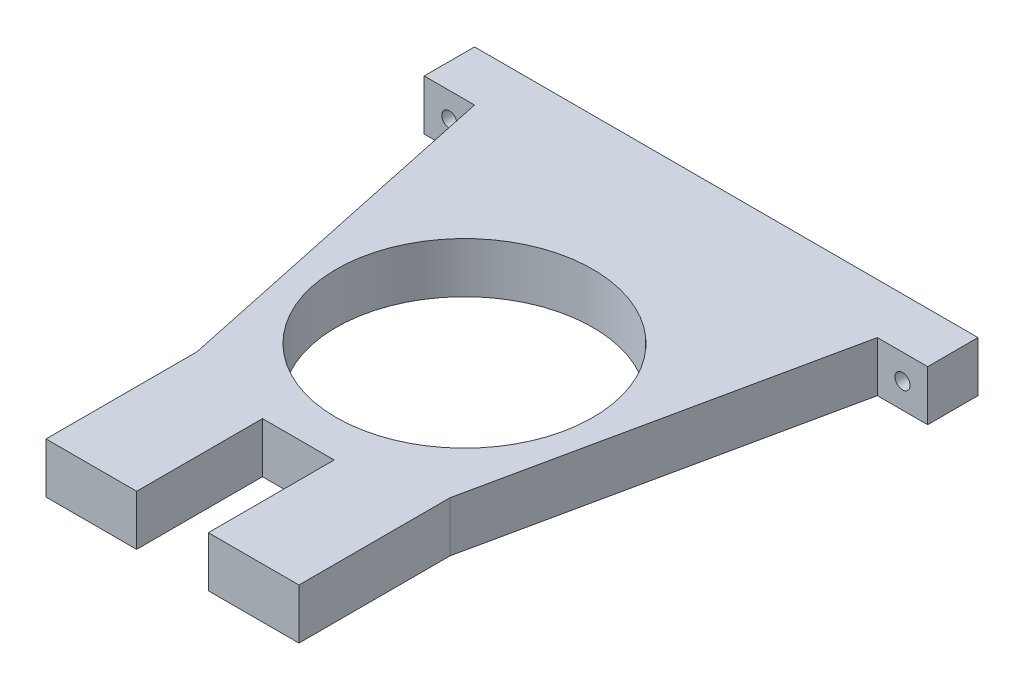
from build123d import *

# Parameters (mm, degrees)
CROQUIS1_R              = 25.5
SALIENTE_EXTRUIR1_DEPTH = 10
CORTAR_EXTRUIR1_REACH   = 12
CROQUIS2_R              = 1.5


with BuildPart() as part:
    # Croquis1 → Saliente-Extruir1 (new body)
    with BuildSketch(Plane(origin=(0, 0, 0), x_dir=(1, 0, 0), z_dir=(0, 1, 0))):
        Polygon((40, -10), (50, -10), (50, 0), (-50, 0), (-50, -10), (-40, -10), (-25.121040683, -80), (-25.121040683, -110), (-7.121040683, -110), (-7.121040683, -85), (7.121040683, -85), (7.121040683, -110), (25.121040683, -110), (25.121040683, -80), align=None)
        with Locations((0, -52)):
            Circle(CROQUIS1_R, mode=Mode.SUBTRACT)
    extrude(amount=SALIENTE_EXTRUIR1_DEPTH)

    # Croquis2 → Cortar-Extruir1 (cut, up to next)
    with BuildSketch(Plane.XY.offset(10), mode=Mode.PRIVATE) as cortar_extruir1_sk1:
        with Locations((-45, 5)):
            Circle(CROQUIS2_R)
    cortar_extruir1_tool1 = extrude(cortar_extruir1_sk1.sketch, amount=-CORTAR_EXTRUIR1_REACH, mode=Mode.PRIVATE) & part.part
    add(cortar_extruir1_tool1.solids().sort_by_distance((-45, 5, 10))[0], mode=Mode.SUBTRACT)
    # Croquis2 → Cortar-Extruir1 (cut, up to next)
    with BuildSketch(Plane.XY.offset(10), mode=Mode.PRIVATE) as cortar_extruir1_sk2:
        with Locations((45, 5)):
            Circle(CROQUIS2_R)
    cortar_extruir1_tool2 = extrude(cortar_extruir1_sk2.sketch, amount=-CORTAR_EXTRUIR1_REACH, mode=Mode.PRIVATE) & part.part
    add(cortar_extruir1_tool2.solids().sort_by_distance((45, 5, 10))[0], mode=Mode.SUBTRACT)


solid = part.part
